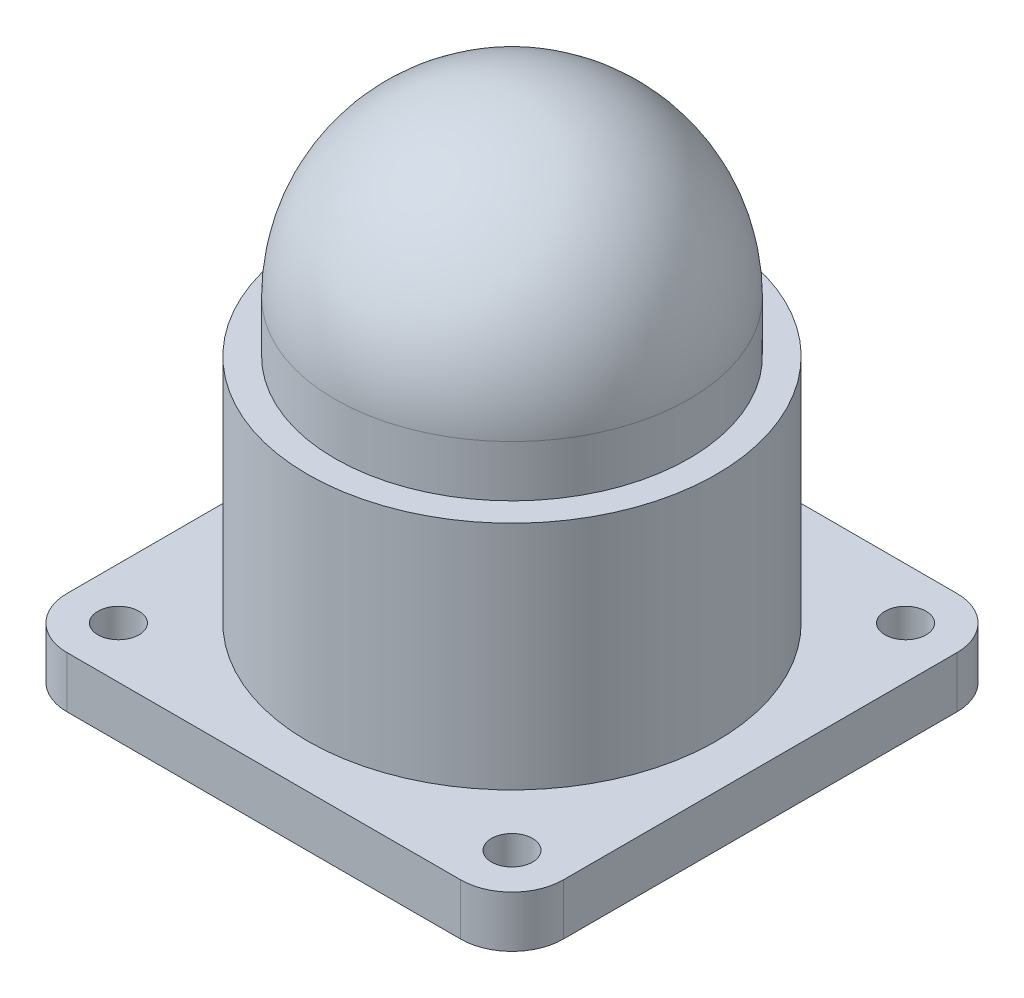
from build123d import *

# Parameters (mm, degrees)
SKETCH1_W           = 29
SKETCH1_H           = 29
SKETCH1_R           = 1.2
BOSS_EXTRUDE1_DEPTH = 3
FILLET1_R           = 3
SKETCH2_R           = 11.95
BOSS_EXTRUDE2_DEPTH = 13.5
SKETCH3_R           = 10.35
BOSS_EXTRUDE3_DEPTH = 3


with BuildPart() as part:
    # Sketch1 → Boss-Extrude1 (new body)
    with BuildSketch(Plane(origin=(0, 0, 0), x_dir=(1, 0, 0), z_dir=(0, 1, 0))):
        with Locations((14.5, 14.5)):
            Rectangle(SKETCH1_W, SKETCH1_H)
        with Locations((3, 26)):
            Circle(SKETCH1_R, mode=Mode.SUBTRACT)
        with Locations((26, 26)):
            Circle(SKETCH1_R, mode=Mode.SUBTRACT)
        with Locations((26, 3)):
            Circle(SKETCH1_R, mode=Mode.SUBTRACT)
        with Locations((3, 3)):
            Circle(SKETCH1_R, mode=Mode.SUBTRACT)
    extrude(amount=BOSS_EXTRUDE1_DEPTH)

    # Fillet1
    fillet1_edges = [part.edges().sort_by_distance(p)[0] for p in [
        (0, 1.5, -29),
        (29, 1.5, -29),
        (29, 1.5, 0),
        (0, 1.5, 0),
    ]]
    fillet(fillet1_edges, radius=FILLET1_R)

    # Sketch2 → Boss-Extrude2 (add)
    with BuildSketch(Plane(origin=(0, 3, 0), x_dir=(1, 0, 0), z_dir=(0, 1, 0))):
        with Locations((14.5, 14.5)):
            Circle(SKETCH2_R)
    extrude(amount=BOSS_EXTRUDE2_DEPTH)

    # Sketch3 → Boss-Extrude3 (add)
    with BuildSketch(Plane(origin=(0, 16.5, 0), x_dir=(1, 0, 0), z_dir=(0, 1, 0))):
        with Locations((14.5, 14.5)):
            Circle(SKETCH3_R)
    extrude(amount=BOSS_EXTRUDE3_DEPTH)

    # Sketch4 → Revolve1 (revolve)
    with BuildSketch(Plane.XY.offset(-14.5)):
        with BuildLine():
            Line((14.5, 19.5), (14.5, 29.85))
            ThreePointArc((14.5, 29.85), (21.818555185, 26.818555185), (24.85, 19.5))
            Line((24.85, 19.5), (14.5, 19.5))
        make_face()
    revolve(axis=Axis((14.5, 19.5, -14.5), (0, 1, 0)))


solid = part.part
